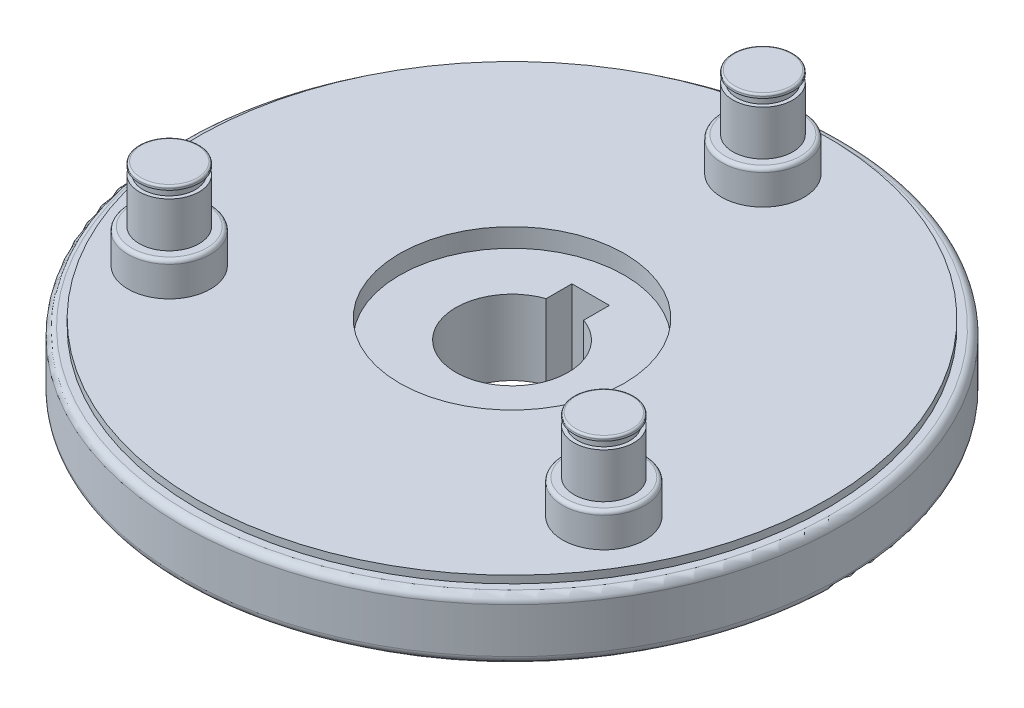
from build123d import *

# Parameters (mm, degrees)
SKETCH1_R                = 44
BOSS_EXTRUDE1_DEPTH      = 10
SKETCH2_R                = 44
SKETCH2_R_2              = 42
CUT_EXTRUDE1_DEPTH       = 1
FILLET1_R                = 1
SKETCH3_R                = 15
CUT_EXTRUDE2_DEPTH       = 2.5
SKETCH4_R                = 7.5
CUT_EXTRUDE3_DEPTH       = 65.5
SKETCH5_W                = 5
SKETCH5_H                = 6
CUT_EXTRUDE4_DEPTH       = 65.5
SKETCH7_R                = 15
CUT_EXTRUDE5_DEPTH       = 2
SKETCH8_R                = 13.5
BOSS_EXTRUDE2_DEPTH      = 4.5
CHAMFER1_SIZE            = 1.5
SKETCH9_R                = 5.5
BOSS_EXTRUDE3_DEPTH      = 12
SKETCH10_R               = 5.5
SKETCH10_R_2             = 4
CUT_EXTRUDE6_DEPTH       = 7.5
FILLET2_R                = 0.5
SKETCH11_R               = 4
SKETCH11_R_2             = 3.5
CUT_EXTRUDE7_DEPTH       = 1.5
SKETCH12_R               = 4
BOSS_EXTRUDE4_DEPTH      = 0.5
FILLET3_R                = 0.25
CIRPATTERN1_COUNT        = 3
FILLET2_OF_CIRPATTERN1_R = 0.5
FILLET3_OF_CIRPATTERN1_R = 0.25


with BuildPart() as part:
    # Sketch1 → Boss-Extrude1 (new body)
    with BuildSketch(Plane(origin=(0, 0, 0), x_dir=(1, 0, 0), z_dir=(0, 1, 0))):
        Circle(SKETCH1_R)
    extrude(amount=BOSS_EXTRUDE1_DEPTH)

    # Sketch2 → Cut-Extrude1 (cut)
    with BuildSketch(Plane(origin=(0, 10, 0), x_dir=(1, 0, 0), z_dir=(0, 1, 0))):
        Circle(SKETCH2_R)
        Circle(SKETCH2_R_2, mode=Mode.SUBTRACT)
    cut_extrude1 = extrude(amount=-CUT_EXTRUDE1_DEPTH, mode=Mode.SUBTRACT)

    # Mirror1: Cut-Extrude1 across plane
    add(cut_extrude1.mirror(Plane(origin=(0, 5, 0), x_dir=(0, 0, 1), z_dir=(0, -1, 0))), mode=Mode.SUBTRACT)

    # Fillet1
    fillet1_edges = [part.edges().sort_by_distance(p)[0] for p in [
        (-44, 1, 0),
        (-44, 9, 0),
    ]]
    fillet(fillet1_edges, radius=FILLET1_R)

    # Sketch3 → Cut-Extrude2 (cut)
    with BuildSketch(Plane(origin=(0, 10, 0), x_dir=(1, 0, 0), z_dir=(0, 1, 0))):
        Circle(SKETCH3_R)
    extrude(amount=-CUT_EXTRUDE2_DEPTH, mode=Mode.SUBTRACT)

    # Sketch4 → Cut-Extrude3 (cut)
    with BuildSketch(Plane(origin=(0, 7.5, 0), x_dir=(1, 0, 0), z_dir=(0, 1, 0))):
        Circle(SKETCH4_R)
    extrude(amount=-CUT_EXTRUDE3_DEPTH, mode=Mode.SUBTRACT)

    # Sketch5 → Cut-Extrude4 (cut)
    with BuildSketch(Plane(origin=(0, 7.5, 0), x_dir=(1, 0, 0), z_dir=(0, 1, 0))):
        with Locations((0, 7.5)):
            Rectangle(SKETCH5_W, SKETCH5_H)
    extrude(amount=-CUT_EXTRUDE4_DEPTH, mode=Mode.SUBTRACT)

    # Sketch7 → Cut-Extrude5 (cut)
    with BuildSketch(Plane.XZ):
        Circle(SKETCH7_R)
    extrude(amount=-CUT_EXTRUDE5_DEPTH, mode=Mode.SUBTRACT)

    # Sketch8 → Boss-Extrude2 (add)
    with BuildSketch(Plane.XZ.offset(-2)):
        Circle(SKETCH8_R)
        with BuildLine():
            Line((2.5, -10.5), (2.5, -7.071067812))
            ThreePointArc((2.5, -7.071067812), (0, 7.5), (-2.5, -7.071067812))
            Line((-2.5, -7.071067812), (-2.5, -10.5))
            Line((-2.5, -10.5), (2.5, -10.5))
        make_face(mode=Mode.SUBTRACT)
    extrude(amount=BOSS_EXTRUDE2_DEPTH)

    # Chamfer1
    chamfer1_edges = [part.edges().sort_by_distance(p)[0] for p in [
        (-13.5, -2.5, 0),
    ]]
    chamfer(chamfer1_edges, length=CHAMFER1_SIZE)

    # Sketch9 → Boss-Extrude3 (add)
    with BuildSketch(Plane(origin=(0, 10, 0), x_dir=(1, 0, 0), z_dir=(0, 1, 0))):
        with Locations((0, 33.5)):
            Circle(SKETCH9_R)
    boss_extrude3 = extrude(amount=BOSS_EXTRUDE3_DEPTH)

    # Sketch10 → Cut-Extrude6 (cut)
    with BuildSketch(Plane(origin=(0, 22, 0), x_dir=(1, 0, 0), z_dir=(0, 1, 0))):
        with Locations((0, 33.5)):
            Circle(SKETCH10_R)
        with Locations((0, 33.5)):
            Circle(SKETCH10_R_2, mode=Mode.SUBTRACT)
    cut_extrude6 = extrude(amount=-CUT_EXTRUDE6_DEPTH, mode=Mode.SUBTRACT)

    # Fillet2
    fillet2_edges = [part.edges().sort_by_distance(p)[0] for p in [
        (-5.5, 14.5, -33.5),
    ]]
    fillet(fillet2_edges, radius=FILLET2_R)

    # Sketch11 → Cut-Extrude7 (cut)
    with BuildSketch(Plane(origin=(0, 22, 0), x_dir=(1, 0, 0), z_dir=(0, 1, 0))):
        with Locations((0, 33.5)):
            Circle(SKETCH11_R)
        with Locations((0, 33.5)):
            Circle(SKETCH11_R_2, mode=Mode.SUBTRACT)
    cut_extrude7 = extrude(amount=-CUT_EXTRUDE7_DEPTH, mode=Mode.SUBTRACT)

    # Sketch12 → Boss-Extrude4 (add)
    with BuildSketch(Plane(origin=(0, 22, 0), x_dir=(1, 0, 0), z_dir=(0, 1, 0))):
        with Locations((0, 33.5)):
            Circle(SKETCH12_R)
    boss_extrude4 = extrude(amount=-BOSS_EXTRUDE4_DEPTH)

    # Fillet3
    fillet3_edges = [part.edges().sort_by_distance(p)[0] for p in [
        (-4, 22, -33.5),
    ]]
    fillet(fillet3_edges, radius=FILLET3_R)

    # CirPattern1: Boss-Extrude3, Cut-Extrude6, Cut-Extrude7, Boss-Extrude4 ×3 about axis
    cirpattern1_axis = Axis((0, 0, 0), (0, 1, 0))
    for i in range(1, CIRPATTERN1_COUNT):
        add(boss_extrude3.rotate(cirpattern1_axis, i * 360 / CIRPATTERN1_COUNT))
        add(cut_extrude6.rotate(cirpattern1_axis, i * 360 / CIRPATTERN1_COUNT), mode=Mode.SUBTRACT)
        add(cut_extrude7.rotate(cirpattern1_axis, i * 360 / CIRPATTERN1_COUNT), mode=Mode.SUBTRACT)
        add(boss_extrude4.rotate(cirpattern1_axis, i * 360 / CIRPATTERN1_COUNT))

    # Fillet2 of CirPattern1
    fillet2_of_cirpattern1_edges = [part.edges().sort_by_distance(p)[0] for p in [
        (-26.261851027, 14.5, 21.513139721),
        (31.761851027, 14.5, 11.986860279),
    ]]
    fillet(fillet2_of_cirpattern1_edges, radius=FILLET2_OF_CIRPATTERN1_R)

    # Fillet3 of CirPattern1
    fillet3_of_cirpattern1_edges = [part.edges().sort_by_distance(p)[0] for p in [
        (-27.011851027, 22, 20.214101615),
        (31.011851027, 22, 13.285898385),
    ]]
    fillet(fillet3_of_cirpattern1_edges, radius=FILLET3_OF_CIRPATTERN1_R)


solid = part.part
